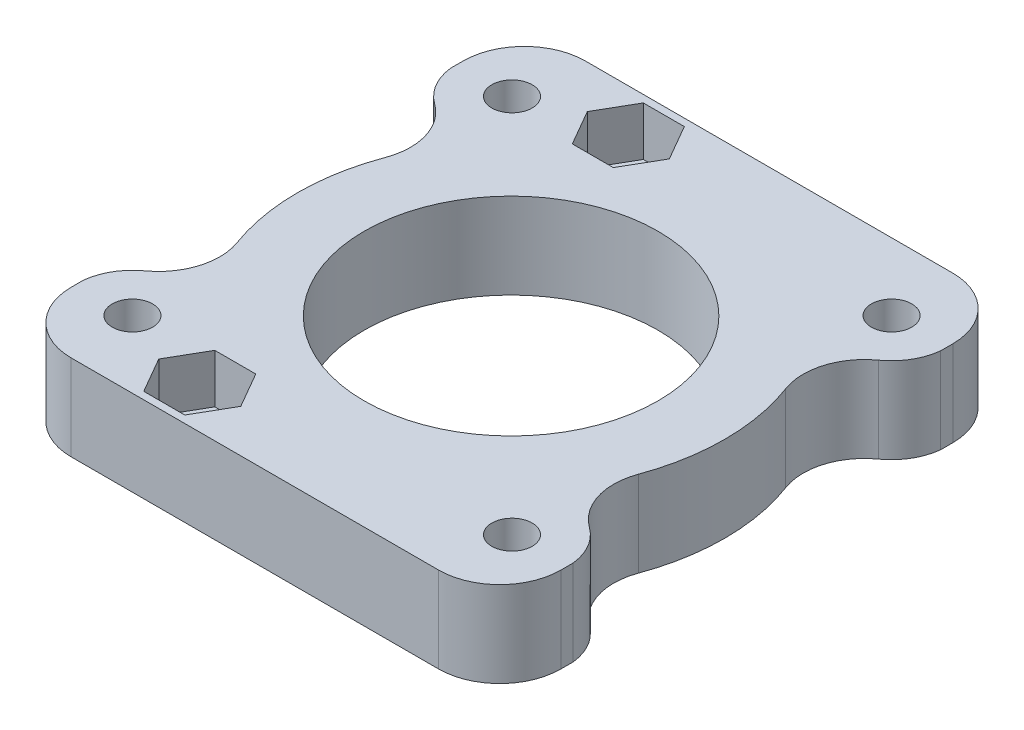
from build123d import *

# Parameters (mm, degrees)
SKETCH_1_R          = 1.65
SKETCH_1_R_2        = 1.6
SKETCH_1_R_3        = 12
EXTRUDE_2_DEPTH     = 7
CUT_EXTRUDE_1_DEPTH = 4
CHAMFER_1_SIZE      = 1.5


with BuildPart() as part:
    # Эскиз1 → Бобышка-Вытянуть2 (new body)
    with BuildSketch(Plane(origin=(0, 0, 0), x_dir=(1, 0, 0), z_dir=(0, 1, 0))):
        with BuildLine():
            ThreePointArc((-18.152308777, -11.756549774), (-19.411562194, -13.145772627), (-20, -14.926053575))
            Line((-20, -14.926053575), (-20, -15.926053575))
            ThreePointArc((-20, -15.926053575), (-18.535533906, -19.461587481), (-15, -20.926053575))
            Line((-15, -20.926053575), (15, -20.926053575))
            ThreePointArc((15, -20.926053575), (18.535533906, -19.461587481), (20, -15.926053575))
            Line((20, -15.926053575), (20, -14.926053575))
            ThreePointArc((20, -14.926053575), (19.411562194, -13.145772627), (18.152308777, -11.756549774))
            ThreePointArc((18.152308777, -11.756549774), (16.300607831, -9.168856683), (16.385075524, -5.988005046))
            ThreePointArc((16.385075524, -5.988005046), (17.444900664, 0.048427023), (16.351577861, 6.078881955))
            ThreePointArc((16.351577861, 6.078881955), (16.257522585, 9.285823976), (18.131827713, 11.889725627))
            ThreePointArc((18.131827713, 11.889725627), (19.405196174, 13.282780162), (20, 15.073946425))
            Line((20, 15.073946425), (20, 16.073946425))
            ThreePointArc((20, 16.073946425), (18.535533906, 19.609480331), (15, 21.073946425))
            Line((15, 21.073946425), (-15, 21.073946425))
            ThreePointArc((-15, 21.073946425), (-18.535533906, 19.609480331), (-20, 16.073946425))
            Line((-20, 16.073946425), (-20, 15.073946425))
            ThreePointArc((-20, 15.073946425), (-19.405196174, 13.282780162), (-18.131827713, 11.889725627))
            ThreePointArc((-18.131827713, 11.889725627), (-16.257522585, 9.285823976), (-16.351577861, 6.078881955))
            ThreePointArc((-16.351577861, 6.078881955), (-17.444900664, 0.048427023), (-16.385075524, -5.988005046))
            ThreePointArc((-16.385075524, -5.988005046), (-16.300607831, -9.168856683), (-18.152308777, -11.756549774))
        make_face()
        with Locations((-15.5, -15.426053575)):
            Circle(SKETCH_1_R, mode=Mode.SUBTRACT)
        with Locations((-8, -17.426053575)):
            Circle(SKETCH_1_R_2, mode=Mode.SUBTRACT)
        with Locations((15.5, -15.426053575)):
            Circle(SKETCH_1_R, mode=Mode.SUBTRACT)
        Circle(SKETCH_1_R_3, mode=Mode.SUBTRACT)
        with Locations((-15.5, 15.573946425)):
            Circle(SKETCH_1_R, mode=Mode.SUBTRACT)
        with Locations((-8, 17.573946425)):
            Circle(SKETCH_1_R_2, mode=Mode.SUBTRACT)
        with Locations((15.5, 15.573946425)):
            Circle(SKETCH_1_R, mode=Mode.SUBTRACT)
    extrude(amount=EXTRUDE_2_DEPTH)

    # Эскиз2 → Вырез-Вытянуть1 (cut)
    with BuildSketch(Plane(origin=(0, 7, 0), x_dir=(1, 0, 0), z_dir=(0, 1, 0))):
        Polygon((-11.348631561, 17.573946425), (-9.674315781, 14.673946425), (-6.325684219, 14.673946425), (-4.651368439, 17.573946425), (-6.325684219, 20.473946425), (-9.674315781, 20.473946425), align=None)
        Polygon((-4.651368439, -17.426053575), (-6.325684219, -14.526053575), (-9.674315781, -14.526053575), (-11.348631561, -17.426053575), (-9.674315781, -20.326053575), (-6.325684219, -20.326053575), align=None)
    extrude(amount=-CUT_EXTRUDE_1_DEPTH, mode=Mode.SUBTRACT)

    # Фаска1
    chamfer_1_edges = [part.edges().sort_by_distance(p)[0] for p in [
        (-17.15, 0, 15.426053575),
        (13.85, 0, 15.426053575),
        (13.85, 0, -15.573946425),
        (-17.15, 0, -15.573946425),
    ]]
    chamfer(chamfer_1_edges, length=CHAMFER_1_SIZE)


solid = part.part
